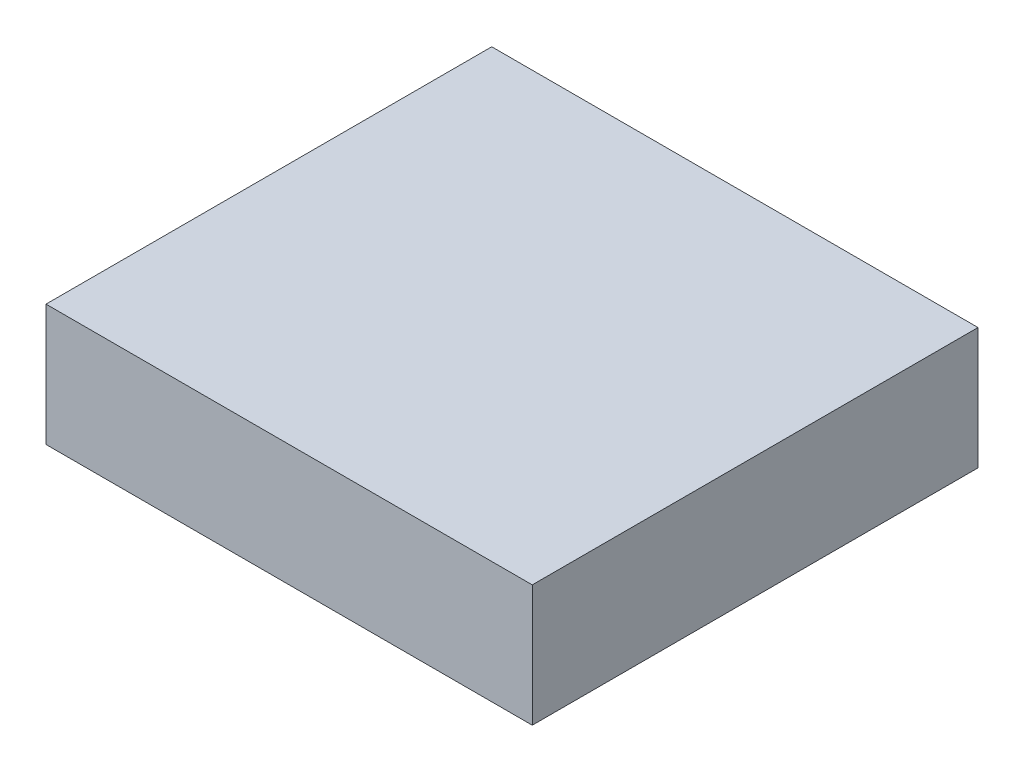
from build123d import *

# Parameters (mm, degrees)
SKETCH1_W           = 152.4
SKETCH1_H           = 139.7
BOSS_EXTRUDE1_DEPTH = 38.1


with BuildPart() as part:
    # Sketch1 → Boss-Extrude1 (new body)
    with BuildSketch(Plane(origin=(0, 0, 0), x_dir=(1, 0, 0), z_dir=(0, 1, 0))):
        with Locations((76.2, 69.85)):
            Rectangle(SKETCH1_W, SKETCH1_H)
    extrude(amount=BOSS_EXTRUDE1_DEPTH)


solid = part.part
